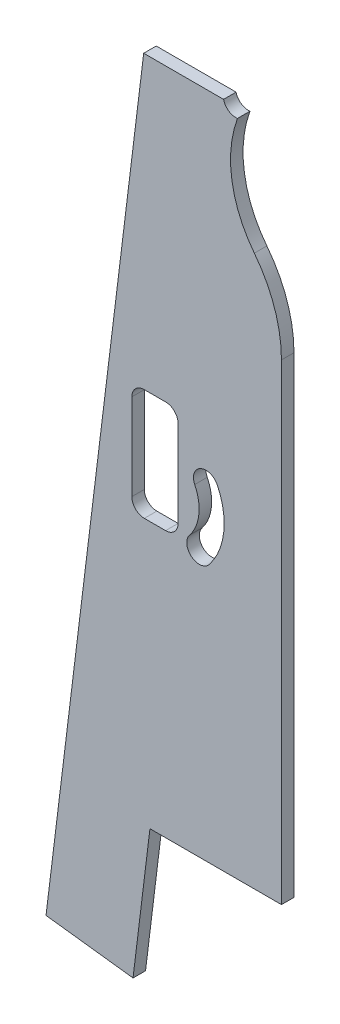
from build123d import *

# Parameters (mm, degrees)
BOSS_EXTRUDE1_DEPTH = 6.35
SKETCH2_R           = 6.35
CUT_EXTRUDE1_DEPTH  = 6.35
CUT_EXTRUDE3_DEPTH  = 6.35
CUT_EXTRUDE4_DEPTH  = 6.35
CUT_EXTRUDE6_DEPTH  = 6.35


with BuildPart() as part:
    # Sketch1 → Boss-Extrude1 (new body)
    with BuildSketch(Plane.XY):
        Polygon((20.505148302, 25.897062134), (-23.613528139, 31.314154449), (25.914173021, 434.684910476), (95.764173021, 434.684910476), (95.764173021, 95.747062134), (29.081649881, 95.747062134), align=None)
    extrude(amount=BOSS_EXTRUDE1_DEPTH)

    # Sketch2 → Cut-Extrude1 (cut)
    with BuildSketch(Plane.XY.offset(6.35)):
        with Locations((72.594859494, 436.135448726)):
            Circle(SKETCH2_R)
    extrude(amount=-CUT_EXTRUDE1_DEPTH, mode=Mode.SUBTRACT)

    # Sketch3 → Cut-Extrude3 (cut)
    with BuildSketch(Plane.XY.offset(6.35)):
        with BuildLine():
            ThreePointArc((59.06996097, 226.736339707), (66.497801827, 244.661042374), (63.213102929, 263.783765471))
            ThreePointArc((63.213102929, 263.783765471), (54.728545327, 266.726091472), (51.786219326, 258.24153387))
            ThreePointArc((51.786219326, 258.24153387), (53.876482261, 246.072528262), (49.149674443, 234.665899293))
            ThreePointArc((49.149674443, 234.665899293), (50.145037914, 225.740976236), (59.06996097, 226.736339707))
        make_face()
    extrude(amount=-CUT_EXTRUDE3_DEPTH, mode=Mode.SUBTRACT)

    # Sketch4 → Cut-Extrude4 (cut)
    with BuildSketch(Plane.XY.offset(6.35)):
        with BuildLine():
            Line((74.295018445, 431.943320697), (82.016159891, 440.361424689))
            Line((82.016159891, 440.361424689), (105.989857785, 438.164600241))
            Line((105.989857785, 438.164600241), (95.764173021, 334.935994434))
            ThreePointArc((95.764173021, 334.935994434), (92.231289046, 356.088107858), (82.016159891, 374.943990437))
            ThreePointArc((82.016159891, 374.943990437), (70.461962448, 402.401475249), (74.295018445, 431.943320697))
        make_face()
    extrude(amount=-CUT_EXTRUDE4_DEPTH, mode=Mode.SUBTRACT)

    # Sketch5 → Cut-Extrude6 (cut)
    with BuildSketch(Plane.XY.offset(6.35)):
        with BuildLine():
            Line((26.231673021, 287.120128567), (37.026673021, 287.120128567))
            ThreePointArc((37.026673021, 287.120128567), (41.516801082, 285.260256628), (43.376673021, 280.770128567))
            Line((43.376673021, 280.770128567), (43.376673021, 236.955128567))
            ThreePointArc((43.376673021, 236.955128567), (41.516801082, 232.465000507), (37.026673021, 230.605128567))
            Line((37.026673021, 230.605128567), (26.231673021, 230.605128567))
            ThreePointArc((26.231673021, 230.605128567), (21.74154496, 232.465000507), (19.881673021, 236.955128567))
            Line((19.881673021, 236.955128567), (19.881673021, 280.770128567))
            ThreePointArc((19.881673021, 280.770128567), (21.74154496, 285.260256628), (26.231673021, 287.120128567))
        make_face()
    extrude(amount=-CUT_EXTRUDE6_DEPTH, mode=Mode.SUBTRACT)


solid = part.part
